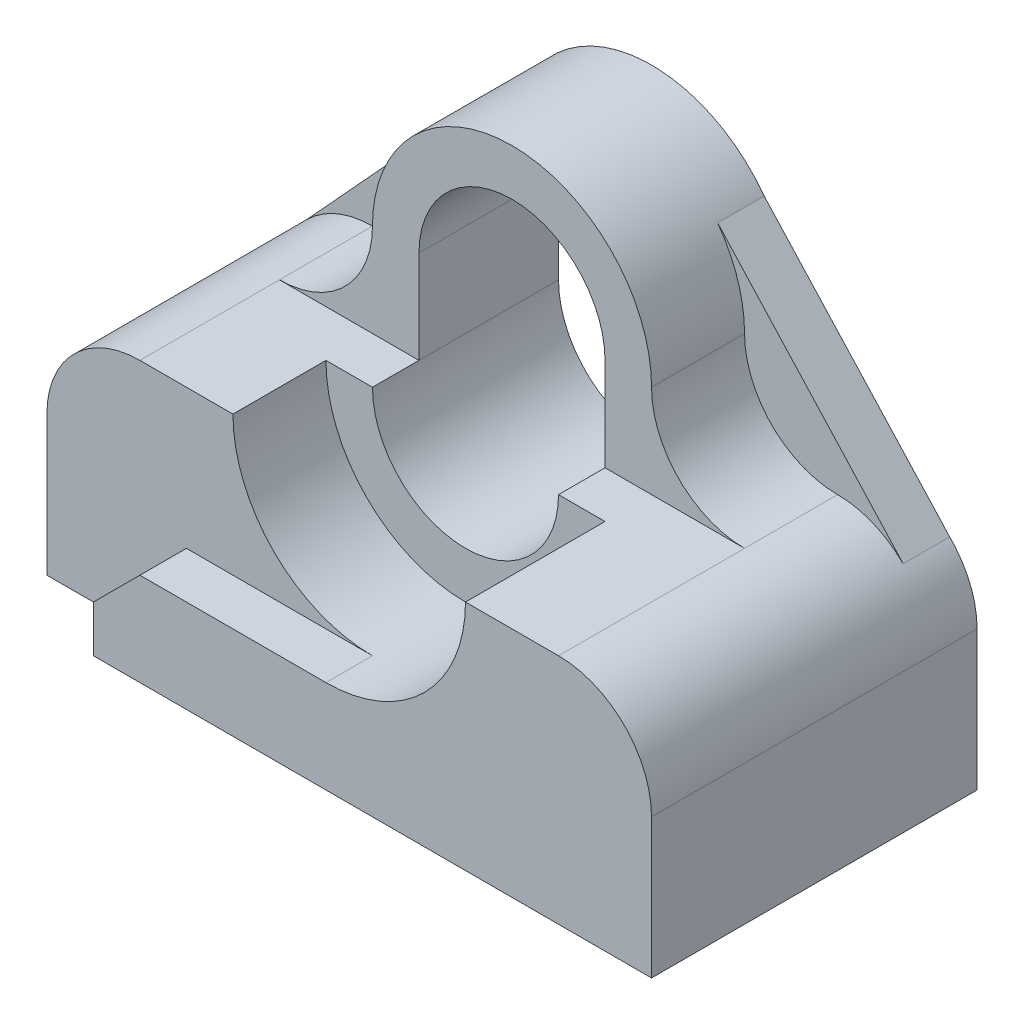
from build123d import *

# Parameters (mm, degrees)
BOSS_EXTRUDE1_DEPTH = 7
BOSS_EXTRUDE2_DEPTH = 1
SKETCH3_W           = 10.974831657
SKETCH3_H           = 5.618667726
CUT_EXTRUDE1_DEPTH  = 4
CUT_EXTRUDE2_DEPTH  = 3
CUT_EXTRUDE3_DEPTH  = 1


with BuildPart() as part:
    # Sketch1 → Boss-Extrude1 (new body)
    with BuildSketch(Plane.XY):
        with BuildLine():
            Line((-7, -2), (-7, -5))
            Line((-7, -5), (7, -5))
            Line((7, -5), (7, -2))
            ThreePointArc((7, -2), (6.414213562, -0.585786438), (5, 0))
            ThreePointArc((5, 0), (3.585786438, 0.585786438), (3, 2))
            ThreePointArc((3, 2), (0, 5), (-3, 2))
            ThreePointArc((-3, 2), (-3.585786438, 0.585786438), (-5, 0))
            ThreePointArc((-5, 0), (-6.414213562, -0.585786438), (-7, -2))
        make_face()
        with BuildLine():
            Line((-2, 0), (-2, 2))
            ThreePointArc((-2, 2), (0, 4), (2, 2))
            Line((2, 2), (2, 0))
            ThreePointArc((2, 0), (0, -2), (-2, 0))
        make_face(mode=Mode.SUBTRACT)
    extrude(amount=BOSS_EXTRUDE1_DEPTH)

    # Sketch2 → Boss-Extrude2 (add)
    with BuildSketch(Plane(origin=(0, 0, 0), x_dir=(-1, 0, 0), z_dir=(0, 0, -1))):
        with BuildLine():
            ThreePointArc((7, -2), (6.880189856, -1.318174432), (6.535113895, -0.718038484))
            Line((6.535113895, -0.718038484), (6.410807281, -0.582388341))
            ThreePointArc((6.410807281, -0.582388341), (5.763143722, -0.151321645), (5, 0))
            ThreePointArc((5, 0), (3.585786438, 0.585786438), (3, 2))
            ThreePointArc((3, 2), (2.851719503, 2.931501945), (2.421536084, 3.77092151))
            ThreePointArc((2.421536084, 3.77092151), (0, 5), (-2.421536084, 3.77092151))
            ThreePointArc((-2.421536084, 3.77092151), (-2.851719503, 2.931501945), (-3, 2))
            ThreePointArc((-3, 2), (-3.585786438, 0.585786438), (-5, 0))
            ThreePointArc((-5, 0), (-5.763143722, -0.151321645), (-6.410807281, -0.582388341))
            Line((-6.410807281, -0.582388341), (-6.535113895, -0.718038484))
            ThreePointArc((-6.535113895, -0.718038484), (-6.880189856, -1.318174432), (-7, -2))
            Line((-7, -2), (-7, -5))
            Line((-7, -5), (7, -5))
            Line((7, -5), (7, -2))
        make_face()
        with BuildLine():
            ThreePointArc((2, 0), (0, -2), (-2, 0))
            Line((-2, 0), (-2, 2))
            ThreePointArc((-2, 2), (0, 4), (2, 2))
            Line((2, 2), (2, 0))
        make_face(mode=Mode.SUBTRACT)
        with BuildLine():
            ThreePointArc((5, 0), (5.763143722, -0.151321645), (6.410807281, -0.582388341))
            Line((6.410807281, -0.582388341), (2.421536084, 3.77092151))
            ThreePointArc((2.421536084, 3.77092151), (2.851719503, 2.931501945), (3, 2))
            ThreePointArc((3, 2), (3.585786438, 0.585786438), (5, 0))
        make_face()
        with BuildLine():
            ThreePointArc((-3, 2), (-2.851719503, 2.931501945), (-2.421536084, 3.77092151))
            Line((-2.421536084, 3.77092151), (-6.410807281, -0.582388341))
            ThreePointArc((-6.410807281, -0.582388341), (-5.763143722, -0.151321645), (-5, 0))
            ThreePointArc((-5, 0), (-3.585786438, 0.585786438), (-3, 2))
        make_face()
    extrude(amount=-BOSS_EXTRUDE2_DEPTH)

    # Sketch3 → Cut-Extrude1 (cut)
    with BuildSketch(Plane.XY.offset(7)):
        with Locations((0.487415829, 2.809333863)):
            Rectangle(SKETCH3_W, SKETCH3_H)
    extrude(amount=-CUT_EXTRUDE1_DEPTH, mode=Mode.SUBTRACT)

    # Sketch4 → Cut-Extrude2 (cut)
    with BuildSketch(Plane.XY.offset(7)):
        with BuildLine():
            Line((3, 2), (3, 0))
            ThreePointArc((3, 0), (0, -3), (-3, 0))
            Line((-3, 0), (-3, 2))
            ThreePointArc((-3, 2), (0, 5), (3, 2))
        make_face()
    extrude(amount=-CUT_EXTRUDE2_DEPTH, mode=Mode.SUBTRACT)

    # Sketch5 → Cut-Extrude3 (cut)
    with BuildSketch(Plane.XY.offset(7)):
        Polygon((0, -3), (-4, -3), (-5, -4), (-5, -5), (-7, -5), (-7, 0), (0, 0), align=None)
    extrude(amount=-CUT_EXTRUDE3_DEPTH, mode=Mode.SUBTRACT)


solid = part.part
